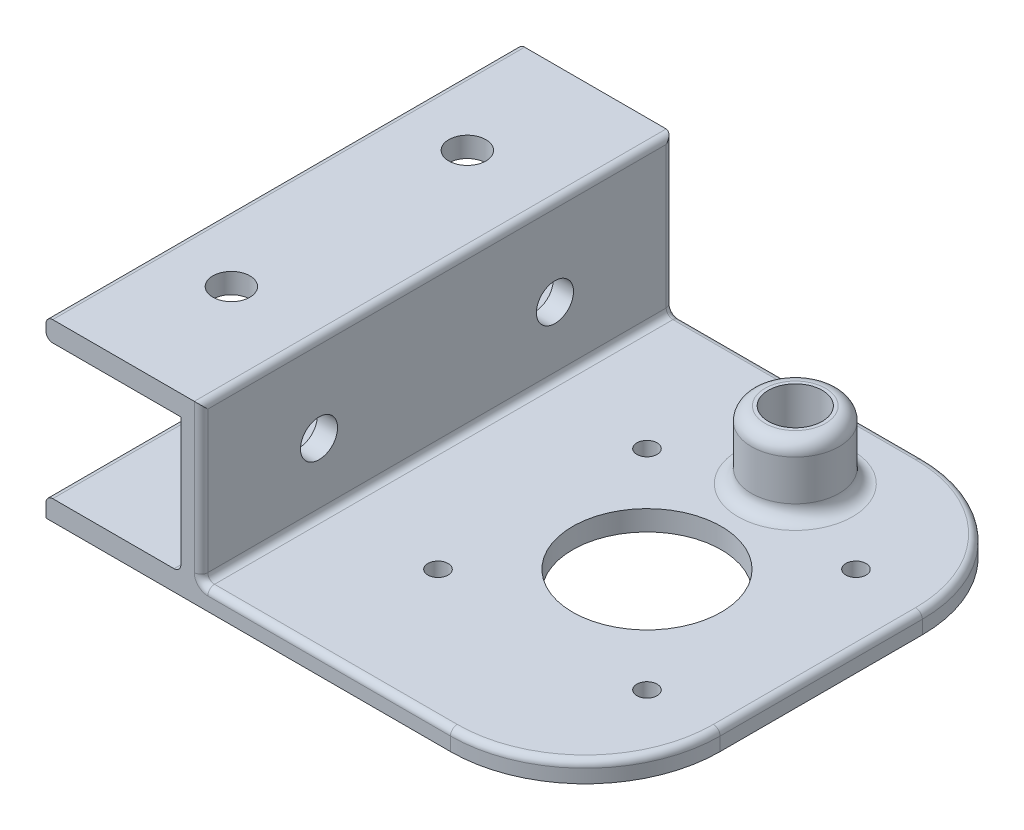
from build123d import *

# Parameters (mm, degrees)
SKETCH1_W                = 20
SKETCH1_H                = 70
SKETCH1_R                = 2.5
SKETCH1_W_2              = 57
SKETCH1_W_3              = 3
BOSS_EXTRUDE1_DEPTH      = 3
SKETCH1_3_W              = 3
SKETCH1_3_H              = 70
BOSS_EXTRUDE2_DEPTH      = 26
SKETCH2_R                = 2.5
CUT_EXTRUDE1_DEPTH       = 17
SKETCH3_R                = 1.5
SKETCH3_R_2              = 11.025
CUT_EXTRUDE2_DEPTH       = 10
FILLET1_R                = 20
BOSS_EXTRUDE4_START      = 26
SKETCH1_4_W              = 20
SKETCH1_4_H              = 70
SKETCH1_4_R              = 2.5
BOSS_EXTRUDE4_DEPTH      = 3
SKETCH4_R                = 6.5
SKETCH4_R_2              = 4
BOSS_EXTRUDE5_DEPTH      = 10
FILLET2_R                = 1
FILLET3_R                = 2
M5_CLEARANCE_HOLE1_D     = 5.5
M5_CLEARANCE_HOLE1_DEPTH = 23
M5_CLEARANCE_HOLE2_D     = 5.5


with BuildPart() as part:
    # Sketch1 → Boss-Extrude1 (new body)
    with BuildSketch(Plane(origin=(0, 0, 0), x_dir=(1, 0, 0), z_dir=(0, 1, 0))):
        with Locations((-30, 0)):
            Rectangle(SKETCH1_W, SKETCH1_H)
        with Locations((-30, -17.5)):
            Circle(SKETCH1_R, mode=Mode.SUBTRACT)
        with Locations((-30, 17.5)):
            Circle(SKETCH1_R, mode=Mode.SUBTRACT)
        with Locations((11.5, 0)):
            Rectangle(SKETCH1_W_2, SKETCH1_H)
        with Locations((-18.5, 0)):
            Rectangle(SKETCH1_W_3, SKETCH1_H)
    extrude(amount=BOSS_EXTRUDE1_DEPTH)

    # Sketch1_3 → Boss-Extrude2 (add)
    with BuildSketch(Plane(origin=(0, 0, 0), x_dir=(1, 0, 0), z_dir=(0, 1, 0))):
        with Locations((-18.5, 0)):
            Rectangle(SKETCH1_3_W, SKETCH1_3_H)
    extrude(amount=BOSS_EXTRUDE2_DEPTH)

    # Sketch2 → Cut-Extrude1 (cut)
    with BuildSketch(Plane(origin=(-17, 0, 0), x_dir=(0, 0, -1), z_dir=(1, 0, 0))):
        with Locations((-17.5, 13)):
            Circle(SKETCH2_R)
        with Locations((17.5, 13)):
            Circle(SKETCH2_R)
    extrude(amount=-CUT_EXTRUDE1_DEPTH, mode=Mode.SUBTRACT)

    # Sketch3 → Cut-Extrude2 (cut)
    with BuildSketch(Plane(origin=(0, 3, 0), x_dir=(1, 0, 0), z_dir=(0, 1, 0))):
        with Locations((-1.350000521, 15.500000521)):
            Circle(SKETCH3_R)
        with Locations((14.15, 0)):
            Circle(SKETCH3_R_2)
        with Locations((29.649999479, 15.499999479)):
            Circle(SKETCH3_R)
        with Locations((29.650000521, -15.500000521)):
            Circle(SKETCH3_R)
        with Locations((-1.349999479, -15.499999479)):
            Circle(SKETCH3_R)
    extrude(amount=-CUT_EXTRUDE2_DEPTH, mode=Mode.SUBTRACT)

    # Fillet1
    fillet1_edges = [part.edges().sort_by_distance(p)[0] for p in [
        (40, 1.5, -35),
        (40, 1.5, 35),
    ]]
    fillet(fillet1_edges, radius=FILLET1_R)

    # Sketch1_4 → Boss-Extrude4 (add)
    with BuildSketch(Plane(origin=(0, 0, 0), x_dir=(1, 0, 0), z_dir=(0, 1, 0)).offset(BOSS_EXTRUDE4_START)):
        with Locations((-30, 0)):
            Rectangle(SKETCH1_4_W, SKETCH1_4_H)
        with Locations((-30, -17.5)):
            Circle(SKETCH1_4_R, mode=Mode.SUBTRACT)
        with Locations((-30, 17.5)):
            Circle(SKETCH1_4_R, mode=Mode.SUBTRACT)
    extrude(amount=-BOSS_EXTRUDE4_DEPTH)

    # Sketch4 → Boss-Extrude5 (add)
    with BuildSketch(Plane(origin=(0, 3, 0), x_dir=(1, 0, 0), z_dir=(0, 1, 0))):
        with Locations((14.15, 22)):
            Circle(SKETCH4_R)
        with Locations((14.15, 22)):
            Circle(SKETCH4_R_2, mode=Mode.SUBTRACT)
    extrude(amount=BOSS_EXTRUDE5_DEPTH)

    # Fillet2
    fillet2_edges = [part.edges().sort_by_distance(p)[0] for p in [
        (-17, 14.5, -35),
        (-17, 14.5, 35),
        (1.5, 3, -35),
        (34.142135624, 3, -29.142135624),
        (40, 3, 0),
        (34.142135624, 3, 29.142135624),
        (-17, 3, 0),
        (-17, 26, 0),
        (1.5, 3, 35),
        (-20, 3, 0),
        (-40, 23, 0),
        (-40, 3, 0),
        (-40, 26, 0),
    ]]
    fillet(fillet2_edges, radius=FILLET2_R)

    # Fillet3
    fillet3_edges = [part.edges().sort_by_distance(p)[0] for p in [
        (7.65, 13, -22),
        (7.65, 3, -22),
    ]]
    fillet(fillet3_edges, radius=FILLET3_R)

    # M5 Clearance Hole1
    with Locations(Plane(origin=(-17, 0, 0), x_dir=(0, 0, -1), z_dir=(1, 0, 0))):
        with Locations((-17.5, 13), (17.5, 13)):
            Hole(M5_CLEARANCE_HOLE1_D / 2, depth=M5_CLEARANCE_HOLE1_DEPTH)

    # M5 Clearance Hole2 (through all)
    with Locations(Plane(origin=(0, 26, 0), x_dir=(1, 0, 0), z_dir=(0, 1, 0))):
        with Locations((-30, -17.5), (-30, 17.5)):
            Hole(M5_CLEARANCE_HOLE2_D / 2)


solid = part.part
